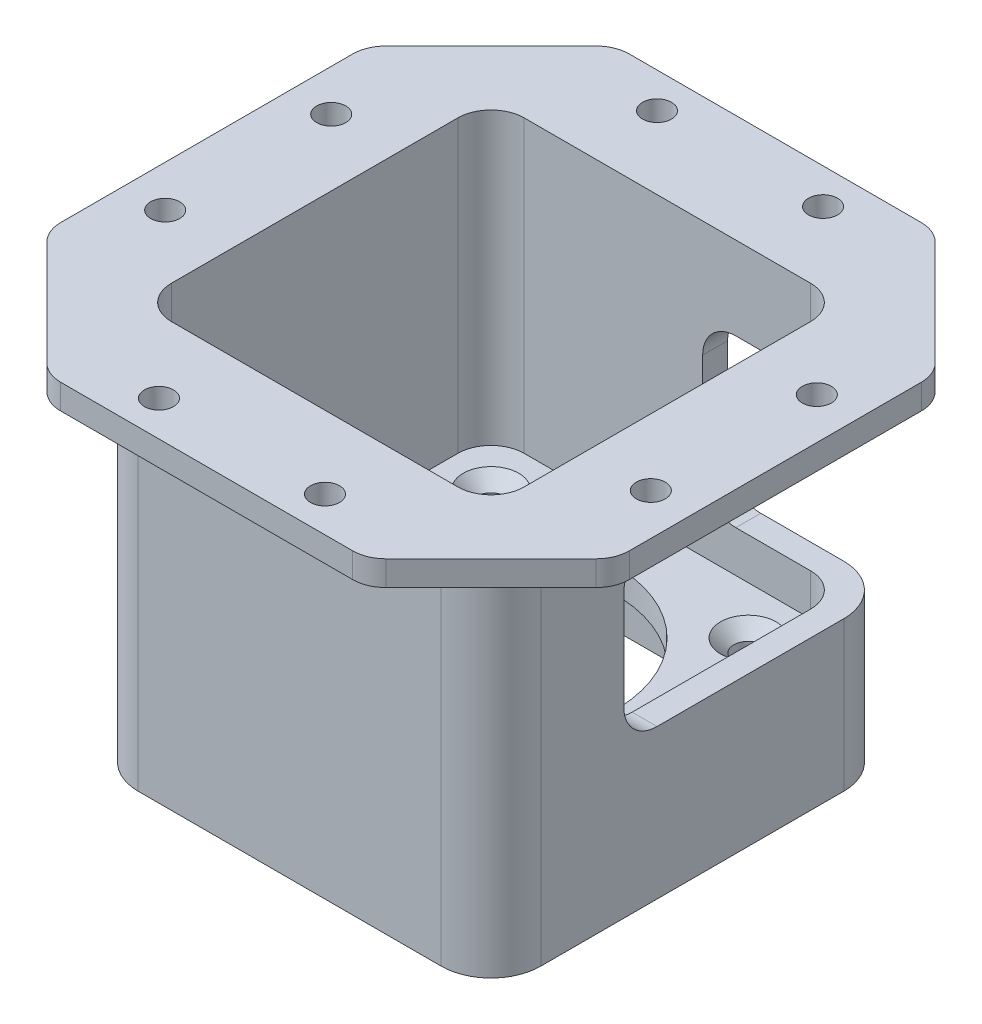
from build123d import *

# Parameters (mm, degrees)
SKETCH2_W           = 48.5
SKETCH2_H           = 48.5
SKETCH2_R           = 15
SKETCH2_R_2         = 1.75
BOSS_EXTRUDE1_DEPTH = 3
SKETCH3_W           = 48.5
SKETCH3_H           = 48.5
SKETCH3_W_2         = 42.5
SKETCH3_H_2         = 42.5
BOSS_EXTRUDE2_DEPTH = 32
SKETCH4_W           = 68.5
SKETCH4_H           = 68.5
SKETCH4_R           = 1.75
SKETCH4_W_2         = 42.5
SKETCH4_H_2         = 42.5
BOSS_EXTRUDE3_DEPTH = 3
CHAMFER1_SIZE       = 15
SKETCH5_W           = 48.5
SKETCH5_H           = 48.5
SKETCH5_W_2         = 42.5
SKETCH5_H_2         = 42.5
BOSS_EXTRUDE4_DEPTH = 10
FILLET1_R           = 6
SKETCH7_W           = 45
SKETCH7_H           = 20
CUT_EXTRUDE2_DEPTH  = 20
FILLET2_R           = 4
CHAMFER2_SIZE       = 1.6
FILLET4_R           = 4
FILLET5_R           = 4
FILLET6_R           = 3


with BuildPart() as part:
    # Sketch2 → Boss-Extrude1 (new body)
    with BuildSketch(Plane(origin=(0, 0, 0), x_dir=(1, 0, 0), z_dir=(0, 1, 0))):
        Rectangle(SKETCH2_W, SKETCH2_H)
        Circle(SKETCH2_R, mode=Mode.SUBTRACT)
        with Locations((-15.5, 15.5)):
            Circle(SKETCH2_R_2, mode=Mode.SUBTRACT)
        with Locations((15.5, 15.5)):
            Circle(SKETCH2_R_2, mode=Mode.SUBTRACT)
        with Locations((15.5, -15.5)):
            Circle(SKETCH2_R_2, mode=Mode.SUBTRACT)
        with Locations((-15.5, -15.5)):
            Circle(SKETCH2_R_2, mode=Mode.SUBTRACT)
    extrude(amount=BOSS_EXTRUDE1_DEPTH)

    # Sketch3 → Boss-Extrude2 (add)
    with BuildSketch(Plane(origin=(0, 3, 0), x_dir=(1, 0, 0), z_dir=(0, 1, 0))):
        Rectangle(SKETCH3_W, SKETCH3_H)
        Rectangle(SKETCH3_W_2, SKETCH3_H_2, mode=Mode.SUBTRACT)
    extrude(amount=BOSS_EXTRUDE2_DEPTH)

    # Sketch4 → Boss-Extrude3 (add)
    with BuildSketch(Plane(origin=(0, 35, 0), x_dir=(1, 0, 0), z_dir=(0, 1, 0))):
        Rectangle(SKETCH4_W, SKETCH4_H)
        with Locations((-10, 30)):
            Circle(SKETCH4_R, mode=Mode.SUBTRACT)
        with Locations((10, 30)):
            Circle(SKETCH4_R, mode=Mode.SUBTRACT)
        with Locations((-29.25, 10)):
            Circle(SKETCH4_R, mode=Mode.SUBTRACT)
        with Locations((-29.25, -10)):
            Circle(SKETCH4_R, mode=Mode.SUBTRACT)
        with Locations((-10, -30)):
            Circle(SKETCH4_R, mode=Mode.SUBTRACT)
        with Locations((10, -30)):
            Circle(SKETCH4_R, mode=Mode.SUBTRACT)
        with Locations((29.25, -10)):
            Circle(SKETCH4_R, mode=Mode.SUBTRACT)
        with Locations((29.25, 10)):
            Circle(SKETCH4_R, mode=Mode.SUBTRACT)
        Rectangle(SKETCH4_W_2, SKETCH4_H_2, mode=Mode.SUBTRACT)
    extrude(amount=BOSS_EXTRUDE3_DEPTH)

    # Chamfer1
    chamfer1_edges = [part.edges().sort_by_distance(p)[0] for p in [
        (-34.25, 36.5, 34.25),
        (34.25, 36.5, 34.25),
        (34.25, 36.5, -34.25),
        (-34.25, 36.5, -34.25),
    ]]
    chamfer(chamfer1_edges, length=CHAMFER1_SIZE)

    # Sketch5 → Boss-Extrude4 (add)
    with BuildSketch(Plane.XZ):
        Rectangle(SKETCH5_W, SKETCH5_H)
        Rectangle(SKETCH5_W_2, SKETCH5_H_2, mode=Mode.SUBTRACT)
    extrude(amount=BOSS_EXTRUDE4_DEPTH)

    # Fillet1
    fillet1_edges = [part.edges().sort_by_distance(p)[0] for p in [
        (-24.25, 12.5, -24.25),
        (24.25, 12.5, -24.25),
        (24.25, 12.5, 24.25),
        (-24.25, 12.5, 24.25),
    ]]
    fillet(fillet1_edges, radius=FILLET1_R)

    # Sketch7 → Cut-Extrude2 (cut)
    with BuildSketch(Plane(origin=(24.25, 0, 0), x_dir=(0, 0, -1), z_dir=(1, 0, 0))):
        with Locations((14.25, 18)):
            Rectangle(SKETCH7_W, SKETCH7_H)
    extrude(amount=-CUT_EXTRUDE2_DEPTH, mode=Mode.SUBTRACT)

    # Fillet2
    fillet2_edges = [part.edges().sort_by_distance(p)[0] for p in [
        (-19.25, 36.5, 34.25),
        (19.25, 36.5, 34.25),
        (-19.25, 36.5, -34.25),
        (19.25, 36.5, -34.25),
        (-34.25, 36.5, 19.25),
        (-34.25, 36.5, -19.25),
        (34.25, 36.5, -19.25),
        (34.25, 36.5, 19.25),
    ]]
    fillet(fillet2_edges, radius=FILLET2_R)

    # Chamfer2
    chamfer2_edges = [part.edges().sort_by_distance(p)[0] for p in [
        (-17.25, 3, -15.5),
        (13.75, 3, -15.5),
        (13.75, 3, 15.5),
        (-17.25, 3, 15.5),
    ]]
    chamfer(chamfer2_edges, length=CHAMFER2_SIZE)

    # Fillet4
    fillet4_edges = [part.edges().sort_by_distance(p)[0] for p in [
        (21.25, 5.5, -21.25),
        (21.25, 33, -21.25),
        (-21.25, 20.5, -21.25),
        (-21.25, 20.5, 21.25),
        (21.25, 20.5, 21.25),
    ]]
    fillet(fillet4_edges, radius=FILLET4_R)

    # Fillet5
    fillet5_edges = [part.edges().sort_by_distance(p)[0] for p in [
        (4.25, 8, -22.75),
        (22.75, 28, 8.25),
        (4.25, 28, -22.75),
        (22.75, 8, 8.25),
    ]]
    fillet(fillet5_edges, radius=FILLET5_R)

    # Fillet6
    fillet6_edges = [part.edges().sort_by_distance(p)[0] for p in [
        (21.25, -5, 21.25),
        (-21.25, -5, 21.25),
        (-21.25, -5, -21.25),
        (21.25, -5, -21.25),
    ]]
    fillet(fillet6_edges, radius=FILLET6_R)


solid = part.part
